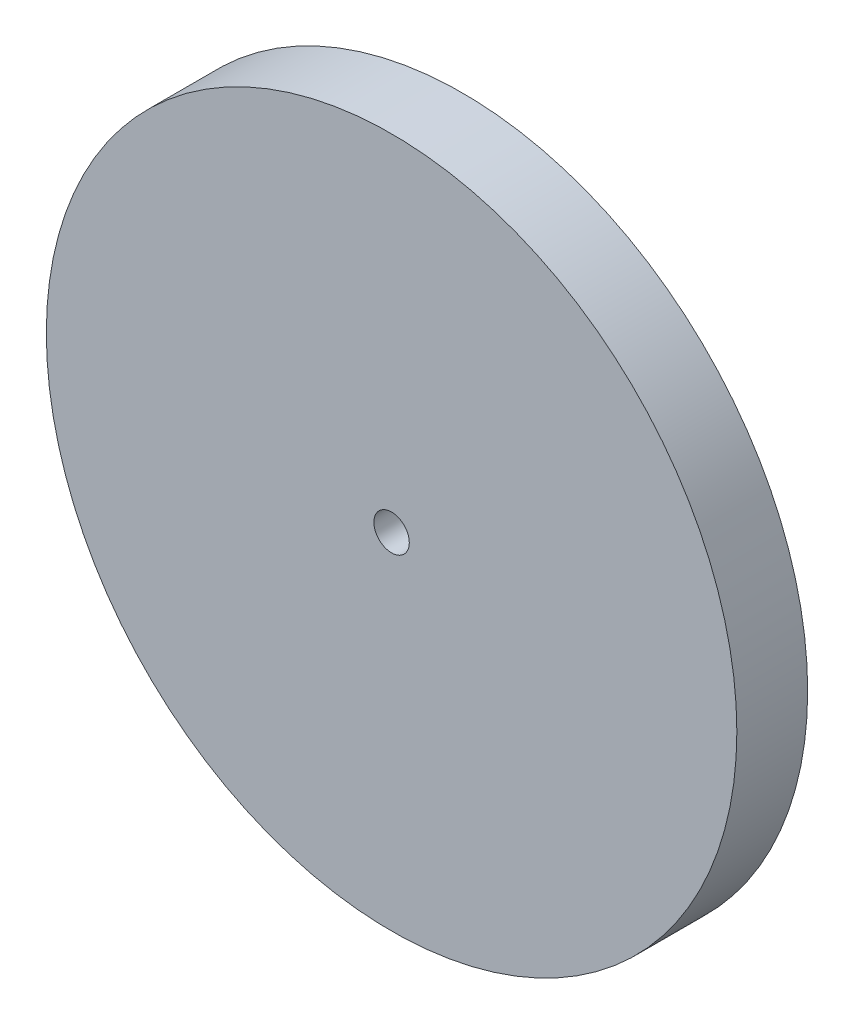
from build123d import *

# Parameters (mm, degrees)
SKETCH_1_R          = 19.5
EXTRUDE_1_DEPTH     = 4
SKETCH_2_R          = 1
CUT_EXTRUDE_1_DEPTH = 5


with BuildPart() as part:
    # 草图1 → 凸台-拉伸1 (new body)
    with BuildSketch(Plane.XY):
        Circle(SKETCH_1_R)
    extrude(amount=EXTRUDE_1_DEPTH)

    # 草图2 → 切除-拉伸1 (cut, through all)
    with BuildSketch(Plane.XY.offset(4)):
        Circle(SKETCH_2_R)
    extrude(amount=-CUT_EXTRUDE_1_DEPTH, mode=Mode.SUBTRACT)


solid = part.part
